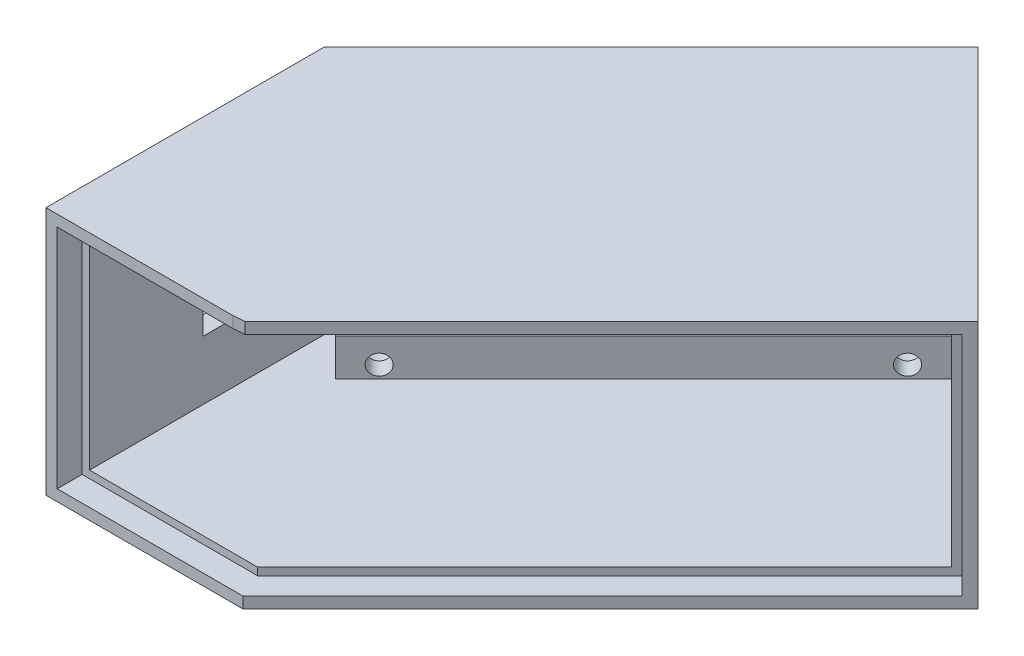
from build123d import *

# Parameters (mm, degrees)
BOSS_EXTRUDE1_DEPTH = 40
SHELL1_T            = -3
BOSS_EXTRUDE2_DEPTH = 4
BOSS_EXTRUDE3_DEPTH = 4
BOSS_EXTRUDE4_DEPTH = 1.8
BOSS_EXTRUDE5_DEPTH = 1.8
SKETCH10_R          = 1.65
CUT_EXTRUDE6_DEPTH  = 41.105
SKETCH11_W          = 12.8
SKETCH11_H          = 15
CUT_EXTRUDE7_DEPTH  = 3
SKETCH12_W          = 69.967359313
SKETCH12_H          = 34
SKETCH12_R          = 1.6
BOSS_EXTRUDE7_DEPTH = 10
SKETCH13_R          = 3.5
CUT_EXTRUDE9_DEPTH  = 10
SKETCH14_W          = 69.967359313
SKETCH14_H          = 22
CUT_EXTRUDE10_DEPTH = 10


with BuildPart() as part:
    # Sketch1 → Boss-Extrude1 (new body)
    with BuildSketch(Plane(origin=(0, 0, 0), x_dir=(1, 0, 0), z_dir=(0, 1, 0))):
        Polygon((-43.359374855, -5.394325428), (-43.359374855, 35.316352691), (9.115019377, 87.790746923), (44.470358437, 52.435407864), (-13.359374855, -5.394325428), align=None)
    extrude(amount=BOSS_EXTRUDE1_DEPTH)

    # Shell1
    shell1_openings = [part.faces().sort_by_distance(p)[0] for p in [
        (15.555491791, 20, -23.520541218),
        (-28.359374855, 20, 5.394325428),
    ]]
    offset(amount=SHELL1_T, openings=shell1_openings, kind=Kind.INTERSECTION)

    # Sketch6 → Boss-Extrude2 (add)
    with BuildSketch(Plane(origin=(-3.982524714, 0, -3.982524714), x_dir=(0.707106781, 0, -0.707106781), z_dir=(0.707106781, 0, 0.707106781))):
        Polygon((-13.260868642, 38.2), (66.722724487, 38.2), (66.722724487, 1.8), (-13.260868642, 1.8), (-13.260868642, 0), (68.522724487, 0), (68.522724487, 40), (-13.260868642, 40), align=None)
    extrude(amount=BOSS_EXTRUDE2_DEPTH)

    # Sketch7 → Boss-Extrude3 (add)
    with BuildSketch(Plane.XY.offset(5.394325428)):
        Polygon((-13.359374855, 1.8), (-41.559374855, 1.8), (-41.559374855, 38.2), (-13.359374855, 38.2), (-13.359374855, 40), (-43.359374855, 40), (-43.359374855, 0), (-13.359374855, 0), align=None)
    extrude(amount=BOSS_EXTRUDE3_DEPTH)

    # Sketch8 → Boss-Extrude4 (add)
    with BuildSketch(Plane.XZ):
        Polygon((-13.359374855, 9.394325428), (-11.702520605, 9.394325428), (-10.53094773, 8.222752552), (-13.359374855, 5.394325428), align=None)
    extrude(amount=-BOSS_EXTRUDE4_DEPTH)

    # Sketch9 → Boss-Extrude5 (add)
    with BuildSketch(Plane(origin=(0, 40, 0), x_dir=(1, 0, 0), z_dir=(0, 1, 0))):
        Polygon((-13.359374855, -5.394325428), (-10.53094773, -8.222752552), (-11.553745116, -9.245549939), (-13.359374855, -9.394325428), align=None)
    extrude(amount=-BOSS_EXTRUDE5_DEPTH)

    # Sketch10 → Cut-Extrude6 (cut, through all)
    with BuildSketch(Plane(origin=(-37.216543429, 0, -37.216543429), x_dir=(0.707106781, 0, -0.707106781), z_dir=(0.707106781, 0, 0.707106781))):
        with Locations((60.522724487, 35)):
            Circle(SKETCH10_R)
        with Locations((60.522724487, 5)):
            Circle(SKETCH10_R)
        with Locations((0.522724487, 35)):
            Circle(SKETCH10_R)
        with Locations((0.522724487, 5)):
            Circle(SKETCH10_R)
    extrude(amount=-CUT_EXTRUDE6_DEPTH, mode=Mode.SUBTRACT)

    # Sketch11 → Cut-Extrude7 (cut)
    with BuildSketch(Plane(origin=(-40.359374855, 0, 0), x_dir=(0, 0, -1), z_dir=(1, 0, 0))):
        with Locations((19.207640819, 20)):
            Rectangle(SKETCH11_W, SKETCH11_H)
    extrude(amount=-CUT_EXTRUDE7_DEPTH, mode=Mode.SUBTRACT)

    # Sketch12 → Boss-Extrude7 (add)
    with BuildSketch(Plane(origin=(-37.216543429, 0, -37.216543429), x_dir=(0.707106781, 0, -0.707106781), z_dir=(0.707106781, 0, 0.707106781))):
        with Locations((30.539044831, 20)):
            Rectangle(SKETCH12_W, SKETCH12_H)
        with Locations((0.522724487, 35)):
            Circle(SKETCH12_R, mode=Mode.SUBTRACT)
        with Locations((60.522724487, 35)):
            Circle(SKETCH12_R, mode=Mode.SUBTRACT)
        with Locations((60.522724487, 5)):
            Circle(SKETCH12_R, mode=Mode.SUBTRACT)
        with Locations((0.522724487, 5)):
            Circle(SKETCH12_R, mode=Mode.SUBTRACT)
    extrude(amount=BOSS_EXTRUDE7_DEPTH)

    # Sketch13 → Cut-Extrude9 (cut)
    with BuildSketch(Plane(origin=(-39.337863773, 0, -39.337863773), x_dir=(-0.707106781, 0, 0.707106781), z_dir=(-0.707106781, 0, -0.707106781))):
        with Locations((-0.522724487, 35)):
            Circle(SKETCH13_R)
        with Locations((-0.522724487, 5)):
            Circle(SKETCH13_R)
        with Locations((-60.522724487, 5)):
            Circle(SKETCH13_R)
        with Locations((-60.522724487, 35)):
            Circle(SKETCH13_R)
    extrude(amount=-CUT_EXTRUDE9_DEPTH, mode=Mode.SUBTRACT)

    # Sketch14 → Cut-Extrude10 (cut)
    with BuildSketch(Plane(origin=(-30.145475617, 0, -30.145475617), x_dir=(0.707106781, 0, -0.707106781), z_dir=(0.707106781, 0, 0.707106781))):
        with Locations((30.539044831, 20)):
            Rectangle(SKETCH14_W, SKETCH14_H)
    extrude(amount=-CUT_EXTRUDE10_DEPTH, mode=Mode.SUBTRACT)


solid = part.part
